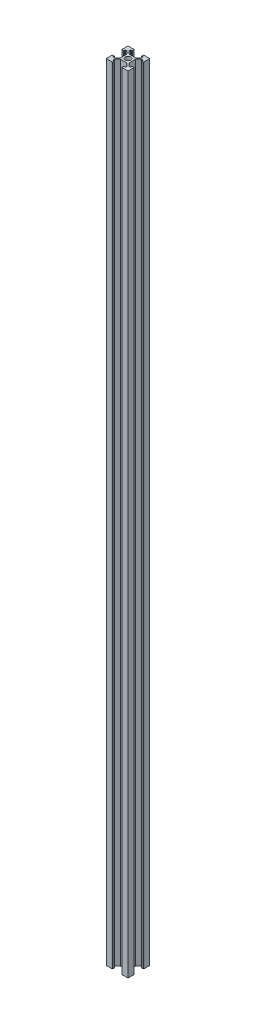
from build123d import *

# Parameters (mm, degrees)
SKETCH1_R           = 2.5
BOSS_EXTRUDE1_DEPTH = 720


with BuildPart() as part:
    # Sketch1 → Boss-Extrude1 (new body)
    with BuildSketch(Plane(origin=(0, 0, 0), x_dir=(1, 0, 0), z_dir=(0, 1, 0))):
        with BuildLine():
            Line((-10, 4.65), (-9.8, 4.65))
            Line((-9.8, 4.65), (-9.8, 4.4))
            ThreePointArc((-9.8, 4.4), (-9.741421356, 4.258578644), (-9.6, 4.2))
            Line((-9.6, 4.2), (-8.4, 4.2))
            ThreePointArc((-8.4, 4.2), (-8.258578644, 4.258578644), (-8.2, 4.4))
            Line((-8.2, 4.4), (-8.2, 5.45))
            ThreePointArc((-8.2, 5.45), (-8.141421356, 5.591421356), (-8, 5.65))
            Line((-8, 5.65), (-6.832842712, 5.65))
            ThreePointArc((-6.832842712, 5.65), (-6.756306026, 5.634775907), (-6.691421356, 5.591421356))
            Line((-6.691421356, 5.591421356), (-4.058578644, 2.958578644))
            ThreePointArc((-4.058578644, 2.958578644), (-4.015224093, 2.893693974), (-4, 2.817157288))
            Line((-4, 2.817157288), (-4, -2.817157288))
            ThreePointArc((-4, -2.817157288), (-4.015224093, -2.893693974), (-4.058578644, -2.958578644))
            Line((-4.058578644, -2.958578644), (-6.691421356, -5.591421356))
            ThreePointArc((-6.691421356, -5.591421356), (-6.756306026, -5.634775907), (-6.832842712, -5.65))
            Line((-6.832842712, -5.65), (-8, -5.65))
            ThreePointArc((-8, -5.65), (-8.141421356, -5.591421356), (-8.2, -5.45))
            Line((-8.2, -5.45), (-8.2, -4.4))
            ThreePointArc((-8.2, -4.4), (-8.258578644, -4.258578644), (-8.4, -4.2))
            Line((-8.4, -4.2), (-9.6, -4.2))
            ThreePointArc((-9.6, -4.2), (-9.741421356, -4.258578644), (-9.8, -4.4))
            Line((-9.8, -4.4), (-9.8, -4.65))
            Line((-9.8, -4.65), (-10, -4.65))
            Line((-10, -4.65), (-10, -9.8))
            ThreePointArc((-10, -9.8), (-9.941421356, -9.941421356), (-9.8, -10))
            Line((-9.8, -10), (-4.65, -10))
            Line((-4.65, -10), (-4.65, -9.8))
            Line((-4.65, -9.8), (-4.4, -9.8))
            ThreePointArc((-4.4, -9.8), (-4.258578644, -9.741421356), (-4.2, -9.6))
            Line((-4.2, -9.6), (-4.2, -8.4))
            ThreePointArc((-4.2, -8.4), (-4.258578644, -8.258578644), (-4.4, -8.2))
            Line((-4.4, -8.2), (-5.45, -8.2))
            ThreePointArc((-5.45, -8.2), (-5.591421356, -8.141421356), (-5.65, -8))
            Line((-5.65, -8), (-5.65, -6.832842712))
            ThreePointArc((-5.65, -6.832842712), (-5.634775907, -6.756306026), (-5.591421356, -6.691421356))
            Line((-5.591421356, -6.691421356), (-2.958578644, -4.058578644))
            ThreePointArc((-2.958578644, -4.058578644), (-2.893693974, -4.015224093), (-2.817157288, -4))
            Line((-2.817157288, -4), (2.817157288, -4))
            ThreePointArc((2.817157288, -4), (2.893693974, -4.015224093), (2.958578644, -4.058578644))
            Line((2.958578644, -4.058578644), (5.591421356, -6.691421356))
            ThreePointArc((5.591421356, -6.691421356), (5.634775907, -6.756306026), (5.65, -6.832842712))
            Line((5.65, -6.832842712), (5.65, -8))
            ThreePointArc((5.65, -8), (5.591421356, -8.141421356), (5.45, -8.2))
            Line((5.45, -8.2), (4.4, -8.2))
            ThreePointArc((4.4, -8.2), (4.258578644, -8.258578644), (4.2, -8.4))
            Line((4.2, -8.4), (4.2, -9.6))
            ThreePointArc((4.2, -9.6), (4.258578644, -9.741421356), (4.4, -9.8))
            Line((4.4, -9.8), (4.65, -9.8))
            Line((4.65, -9.8), (4.65, -10))
            Line((4.65, -10), (9.8, -10))
            ThreePointArc((9.8, -10), (9.941421356, -9.941421356), (10, -9.8))
            Line((10, -9.8), (10, -4.65))
            Line((10, -4.65), (9.8, -4.65))
            Line((9.8, -4.65), (9.8, -4.4))
            ThreePointArc((9.8, -4.4), (9.741421356, -4.258578644), (9.6, -4.2))
            Line((9.6, -4.2), (8.4, -4.2))
            ThreePointArc((8.4, -4.2), (8.258578644, -4.258578644), (8.2, -4.4))
            Line((8.2, -4.4), (8.2, -5.45))
            ThreePointArc((8.2, -5.45), (8.141421356, -5.591421356), (8, -5.65))
            Line((8, -5.65), (6.832842712, -5.65))
            ThreePointArc((6.832842712, -5.65), (6.756306026, -5.634775907), (6.691421356, -5.591421356))
            Line((6.691421356, -5.591421356), (4.058578644, -2.958578644))
            ThreePointArc((4.058578644, -2.958578644), (4.015224093, -2.893693974), (4, -2.817157288))
            Line((4, -2.817157288), (4, 2.817157288))
            ThreePointArc((4, 2.817157288), (4.015224093, 2.893693974), (4.058578644, 2.958578644))
            Line((4.058578644, 2.958578644), (6.691421356, 5.591421356))
            ThreePointArc((6.691421356, 5.591421356), (6.756306026, 5.634775907), (6.832842712, 5.65))
            Line((6.832842712, 5.65), (8, 5.65))
            ThreePointArc((8, 5.65), (8.141421356, 5.591421356), (8.2, 5.45))
            Line((8.2, 5.45), (8.2, 4.4))
            ThreePointArc((8.2, 4.4), (8.258578644, 4.258578644), (8.4, 4.2))
            Line((8.4, 4.2), (9.6, 4.2))
            ThreePointArc((9.6, 4.2), (9.741421356, 4.258578644), (9.8, 4.4))
            Line((9.8, 4.4), (9.8, 4.65))
            Line((9.8, 4.65), (10, 4.65))
            Line((10, 4.65), (10, 9.8))
            ThreePointArc((10, 9.8), (9.941421356, 9.941421356), (9.8, 10))
            Line((9.8, 10), (4.65, 10))
            Line((4.65, 10), (4.65, 9.8))
            Line((4.65, 9.8), (4.4, 9.8))
            ThreePointArc((4.4, 9.8), (4.258578644, 9.741421356), (4.2, 9.6))
            Line((4.2, 9.6), (4.2, 8.4))
            ThreePointArc((4.2, 8.4), (4.258578644, 8.258578644), (4.4, 8.2))
            Line((4.4, 8.2), (5.45, 8.2))
            ThreePointArc((5.45, 8.2), (5.591421356, 8.141421356), (5.65, 8))
            Line((5.65, 8), (5.65, 6.832842712))
            ThreePointArc((5.65, 6.832842712), (5.634775907, 6.756306026), (5.591421356, 6.691421356))
            Line((5.591421356, 6.691421356), (2.958578644, 4.058578644))
            ThreePointArc((2.958578644, 4.058578644), (2.893693974, 4.015224093), (2.817157288, 4))
            Line((2.817157288, 4), (-2.817157288, 4))
            ThreePointArc((-2.817157288, 4), (-2.893693974, 4.015224093), (-2.958578644, 4.058578644))
            Line((-2.958578644, 4.058578644), (-5.591421356, 6.691421356))
            ThreePointArc((-5.591421356, 6.691421356), (-5.634775907, 6.756306026), (-5.65, 6.832842712))
            Line((-5.65, 6.832842712), (-5.65, 8))
            ThreePointArc((-5.65, 8), (-5.591421356, 8.141421356), (-5.45, 8.2))
            Line((-5.45, 8.2), (-4.4, 8.2))
            ThreePointArc((-4.4, 8.2), (-4.258578644, 8.258578644), (-4.2, 8.4))
            Line((-4.2, 8.4), (-4.2, 9.6))
            ThreePointArc((-4.2, 9.6), (-4.258578644, 9.741421356), (-4.4, 9.8))
            Line((-4.4, 9.8), (-4.65, 9.8))
            Line((-4.65, 9.8), (-4.65, 10))
            Line((-4.65, 10), (-9.8, 10))
            ThreePointArc((-9.8, 10), (-9.941421356, 9.941421356), (-10, 9.8))
            Line((-10, 9.8), (-10, 4.65))
        make_face()
        Circle(SKETCH1_R, mode=Mode.SUBTRACT)
    extrude(amount=BOSS_EXTRUDE1_DEPTH)


solid = part.part
